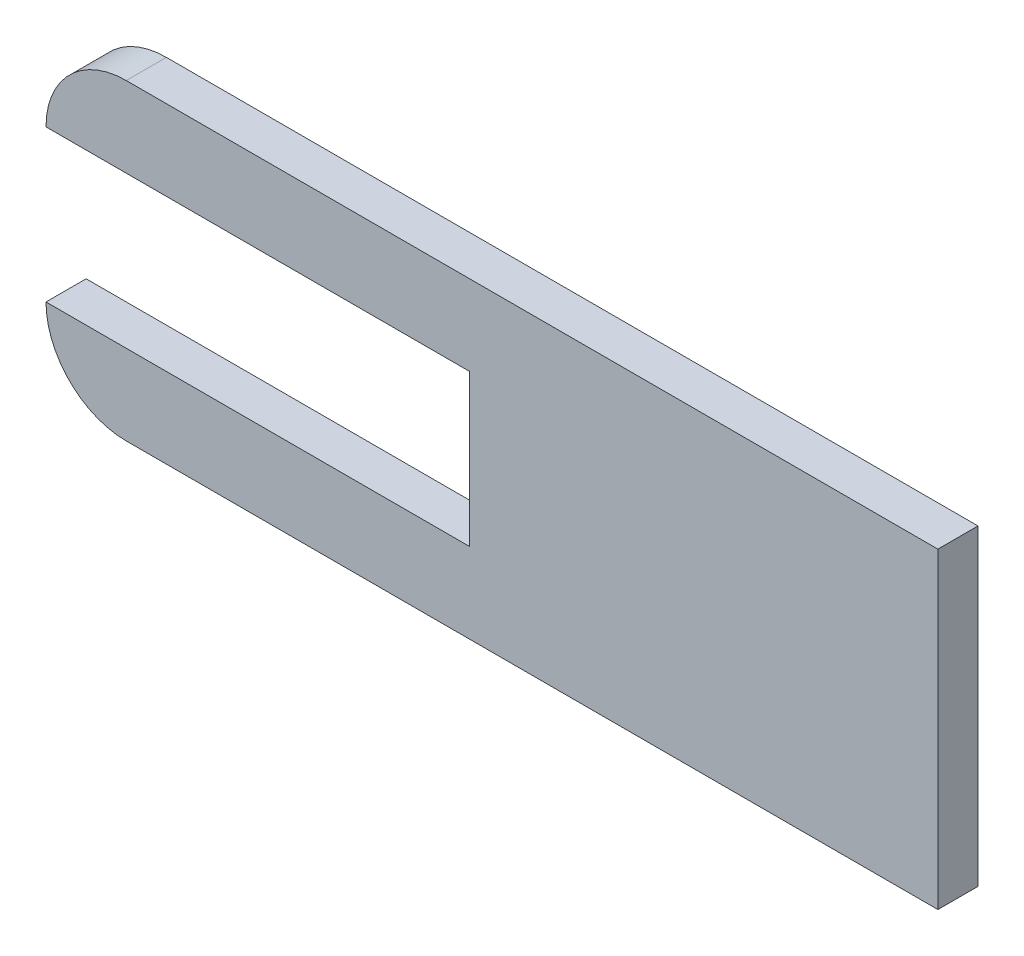
from build123d import *

# Parameters (mm, degrees)
SKETCH1_W           = 254
SKETCH1_H           = 88.9
BOSS_EXTRUDE1_DEPTH = 11.43
FILLET1_R           = 22.86
FILLET2_R           = 22.86
SKETCH2_W           = 11.43
SKETCH2_H           = 43.18
CUT_EXTRUDE1_DEPTH  = 120.65


with BuildPart() as part:
    # Sketch1 → Boss-Extrude1 (new body)
    with BuildSketch(Plane.XY):
        with Locations((127, 44.45)):
            Rectangle(SKETCH1_W, SKETCH1_H)
    extrude(amount=BOSS_EXTRUDE1_DEPTH)

    # Fillet1
    fillet1_edges = [part.edges().sort_by_distance(p)[0] for p in [
        (0, 88.9, 5.715),
    ]]
    fillet(fillet1_edges, radius=FILLET1_R)

    # Fillet2
    fillet2_edges = [part.edges().sort_by_distance(p)[0] for p in [
        (0, 0, 5.715),
    ]]
    fillet(fillet2_edges, radius=FILLET2_R)

    # Sketch2 → Cut-Extrude1 (cut)
    with BuildSketch(Plane.ZY):
        with Locations((5.715, 44.45)):
            Rectangle(SKETCH2_W, SKETCH2_H)
    extrude(amount=-CUT_EXTRUDE1_DEPTH, mode=Mode.SUBTRACT)


solid = part.part
